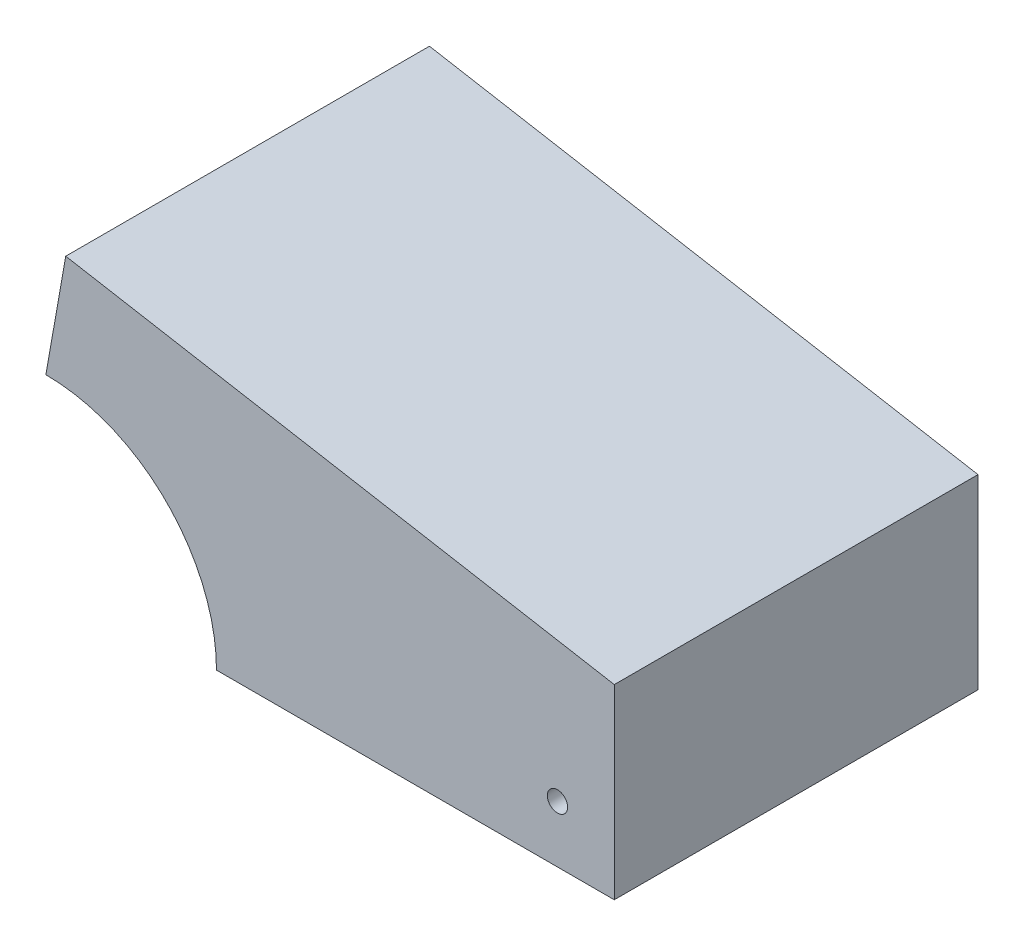
from build123d import *

# Parameters (mm, degrees)
BOSS_EXTRUDE1_DEPTH = 40.64
SKETCH6_R           = 1.1303
CUT_EXTRUDE1_DEPTH  = 158.779215984
SKETCH7_W           = 195.523307817
SKETCH7_H           = 195.523307817
CUT_EXTRUDE2_DEPTH  = 158.779215984
SKETCH8_R           = 1.1303
CUT_EXTRUDE3_DEPTH  = 158.779215984
SKETCH9_R           = 19.05
CUT_EXTRUDE4_DEPTH  = 158.779215984


with BuildPart() as part:
    # Sweep3: sweep along a path in Sketch2
    with BuildLine(Plane.XY) as sweep3_path:
        Line((-111.378641457, -46.568583299), (-11.322173751, -64.21123815))
        ThreePointArc((-11.322173751, -64.21123815), (53.410187761, -37.398216088), (56.466415172, 32.6009))
        Line((56.466415172, 32.6009), (37.416415172, 65.596467884))
    # 3DSketch1 → Sweep3 (sweep)
    with BuildSketch(Plane(origin=(-117.024291009, -78.586652965, -20.32), x_dir=(0.051794909001673446, 0.2937435257699459, 0.9544799780350292), z_dir=(0.984807753012208, -0.17364817766693055, 0))):
        Polygon((0, 0), (3.788092413, -12.121895721), (42.57815872, 0), (38.790066307, 12.121895721), align=None)
    sweep(path=sweep3_path.line)

    # Sketch5 → Boss-Extrude1 (add)
    with BuildSketch(Plane.XY.offset(20.32)):
        with BuildLine():
            Line((-16.967823303, -96.229307816), (-117.024291009, -78.586652965))
            Line((-117.024291009, -78.586652965), (-117.024291009, -97.7138))
            Line((-117.024291009, -97.7138), (3.02e-07, -97.7138))
            ThreePointArc((3.02e-07, -97.7138), (-8.516318665, -97.341969504), (-16.967823303, -96.229307816))
        make_face()
        with BuildLine():
            ThreePointArc((97.7138, -9e-08), (69.09409067, -69.094090521), (3.02e-07, -97.7138))
            Line((3.02e-07, -97.7138), (97.7138, -97.7138))
            Line((97.7138, -97.7138), (97.7138, -9e-08))
        make_face()
        with BuildLine():
            ThreePointArc((84.6226331, 48.8569), (94.384283017, 25.290192366), (97.7138, -9e-08))
            Line((97.7138, -9e-08), (97.7138, 81.852467884))
            Line((97.7138, 81.852467884), (65.5726331, 81.852467884))
            Line((65.5726331, 81.852467884), (84.6226331, 48.8569))
        make_face()
    extrude(amount=-BOSS_EXTRUDE1_DEPTH)

    # Sketch6 → Cut-Extrude1 (cut, through all)
    with BuildSketch(Plane.XY.offset(20.32)):
        with Locations((91.3638, -91.3638)):
            Circle(SKETCH6_R)
        with Locations((-41.9735, -91.3638)):
            Circle(SKETCH6_R)
    extrude(amount=-CUT_EXTRUDE1_DEPTH, mode=Mode.SUBTRACT)

    # Sketch7 → Cut-Extrude2 (cut, through all)
    with BuildSketch(Plane.XY.offset(20.32)):
        with Locations((44.2373629, 0.047853909)):
            Rectangle(SKETCH7_W, SKETCH7_H)
    extrude(amount=-CUT_EXTRUDE2_DEPTH, mode=Mode.SUBTRACT)

    # Sketch8 → Cut-Extrude3 (cut, through all)
    with BuildSketch(Plane.XY.offset(20.32)):
        with Locations((-59.874291009, -91.3638)):
            Circle(SKETCH8_R)
    extrude(amount=-CUT_EXTRUDE3_DEPTH, mode=Mode.SUBTRACT)

    # Sketch9 → Cut-Extrude4 (cut, through all)
    with BuildSketch(Plane.XY.offset(20.32)):
        with Locations((-117.024291009, -97.7138)):
            Circle(SKETCH9_R)
    extrude(amount=-CUT_EXTRUDE4_DEPTH, mode=Mode.SUBTRACT)


solid = part.part
